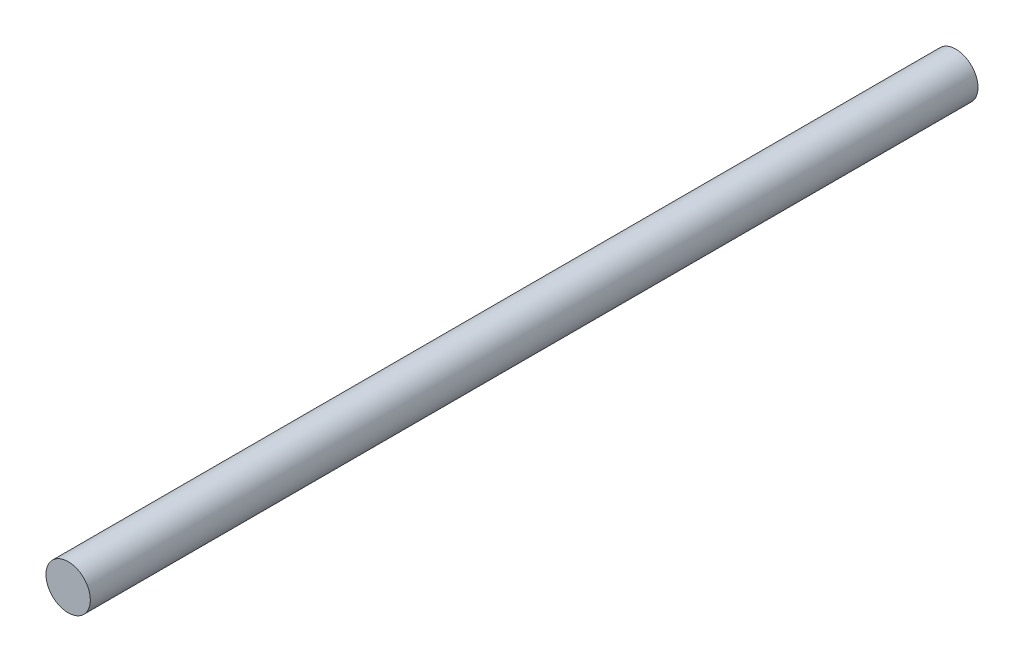
from build123d import *

# Parameters (mm, degrees)
SKETCH1_R           = 2
BOSS_EXTRUDE1_DEPTH = 80


with BuildPart() as part:
    # Sketch1 → Boss-Extrude1 (new body)
    with BuildSketch(Plane.XY):
        Circle(SKETCH1_R)
    extrude(amount=BOSS_EXTRUDE1_DEPTH)


solid = part.part
